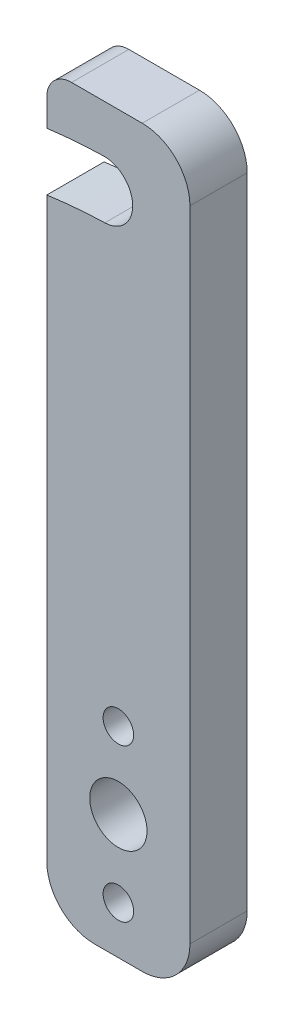
from build123d import *

# Parameters (mm, degrees)
ESBO_O1_R                = 1.6
ESBO_O1_R_2              = 3
RESSALTO_EXTRUS_O1_DEPTH = 6
FILETE1_R                = 5
FILETE2_R                = 2.6


with BuildPart() as part:
    # Esboço1 → Ressalto-extrusão1 (new body)
    with BuildSketch(Plane.XY):
        with BuildLine():
            Line((-7.5, 26.977225559), (-7.5, -38.489430519))
            Line((-7.5, -38.489430519), (7.5, -38.489430519))
            Line((7.5, -38.489430519), (7.5, 38.489430519))
            Line((7.5, 38.489430519), (-7.5, 38.489430519))
            Line((-7.5, 38.489430519), (-7.5, 33.031933101))
            ThreePointArc((-7.5, 33.031933101), (-4.54537196, 33.335220723), (-1.579224698, 33.489430519))
            ThreePointArc((-1.579224698, 33.489430519), (1.5, 30.570804942), (-1.418625577, 27.491580244))
            ThreePointArc((-1.418625577, 27.491580244), (-4.466722594, 27.322011321), (-7.5, 26.977225559))
        make_face()
        with Locations((0, -33.489430519)):
            Circle(ESBO_O1_R, mode=Mode.SUBTRACT)
        with Locations((0, -25.489430519)):
            Circle(ESBO_O1_R_2, mode=Mode.SUBTRACT)
        with Locations((0, -17.489430519)):
            Circle(ESBO_O1_R, mode=Mode.SUBTRACT)
    extrude(amount=RESSALTO_EXTRUS_O1_DEPTH)

    # Filete1
    filete1_edges = [part.edges().sort_by_distance(p)[0] for p in [
        (7.5, 38.489430519, 3),
        (7.5, -38.489430519, 3),
        (-7.5, -38.489430519, 3),
    ]]
    fillet(filete1_edges, radius=FILETE1_R)

    # Filete2
    filete2_edges = [part.edges().sort_by_distance(p)[0] for p in [
        (-7.5, 38.489430519, 3),
    ]]
    fillet(filete2_edges, radius=FILETE2_R)


solid = part.part
